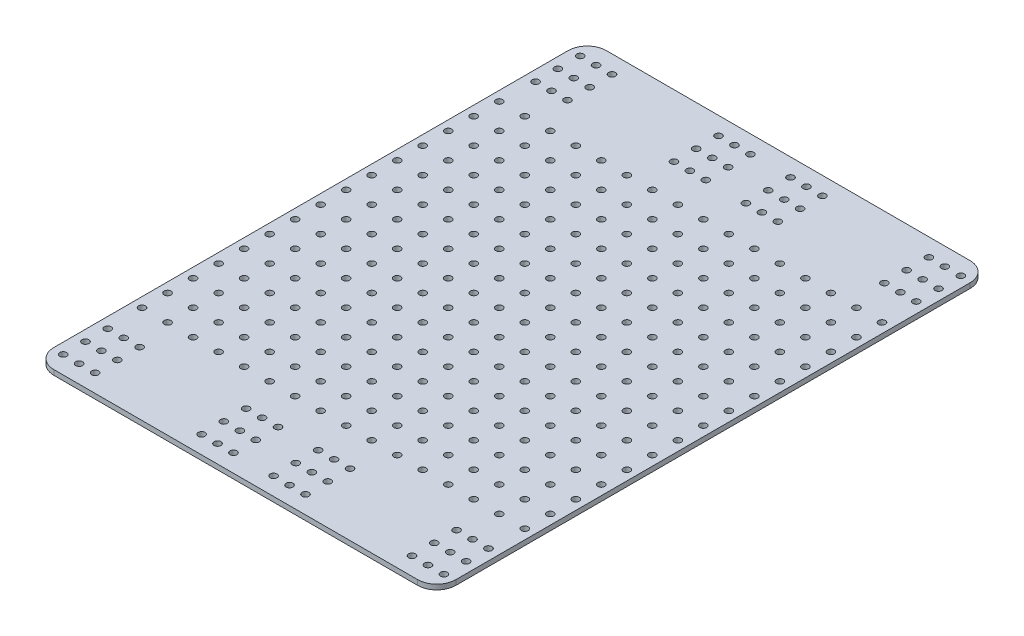
from build123d import *

# Parameters (mm, degrees)
SKETCH2_W            = 200.117666866
SKETCH2_H            = 275
BOSS_EXTRUDE1_DEPTH  = 2.5
M3_CLEARANCE_HOLE1_D = 3.4
MIRROR2_COPY_1_D     = 3.4
FILLET1_R            = 9.525
M3_CLEARANCE_HOLE2_D = 3.4
LPATTERN1_COUNT      = 8
LPATTERN1_PITCH      = 12.7
LPATTERN1_COUNT_DIR2 = 8
LPATTERN1_PITCH_DIR2 = 12.7
MIRROR3_COPY_1_D     = 3.4
MIRROR3_COPY_2_D     = 3.4
MIRROR3_COPY_3_D     = 3.4
MIRROR3_COPY_4_D     = 3.4
MIRROR3_COPY_5_D     = 3.4
MIRROR3_COPY_6_D     = 3.4
MIRROR3_COPY_7_D     = 3.4
MIRROR3_COPY_8_D     = 3.4
MIRROR3_COPY_9_D     = 3.4
MIRROR3_COPY_10_D    = 3.4
MIRROR3_COPY_11_D    = 3.4
MIRROR3_COPY_12_D    = 3.4
MIRROR3_COPY_13_D    = 3.4
MIRROR3_COPY_14_D    = 3.4
MIRROR3_COPY_15_D    = 3.4
MIRROR3_COPY_16_D    = 3.4
MIRROR3_COPY_17_D    = 3.4
MIRROR3_COPY_18_D    = 3.4
MIRROR3_COPY_19_D    = 3.4
MIRROR3_COPY_20_D    = 3.4
MIRROR3_COPY_21_D    = 3.4
MIRROR3_COPY_22_D    = 3.4
MIRROR3_COPY_23_D    = 3.4
MIRROR3_COPY_24_D    = 3.4
MIRROR3_COPY_25_D    = 3.4
MIRROR3_COPY_26_D    = 3.4
MIRROR3_COPY_27_D    = 3.4
MIRROR3_COPY_28_D    = 3.4
MIRROR3_COPY_29_D    = 3.4
MIRROR3_COPY_30_D    = 3.4
MIRROR3_COPY_31_D    = 3.4
MIRROR3_COPY_32_D    = 3.4
MIRROR3_COPY_33_D    = 3.4
MIRROR3_COPY_34_D    = 3.4
MIRROR3_COPY_35_D    = 3.4
MIRROR3_COPY_36_D    = 3.4
MIRROR3_COPY_37_D    = 3.4
MIRROR3_COPY_38_D    = 3.4
MIRROR3_COPY_39_D    = 3.4
MIRROR3_COPY_40_D    = 3.4
MIRROR3_COPY_41_D    = 3.4
MIRROR3_COPY_42_D    = 3.4
MIRROR3_COPY_43_D    = 3.4
MIRROR3_COPY_44_D    = 3.4
MIRROR3_COPY_45_D    = 3.4
MIRROR3_COPY_46_D    = 3.4
MIRROR3_COPY_47_D    = 3.4
MIRROR3_COPY_48_D    = 3.4
MIRROR3_COPY_49_D    = 3.4
MIRROR3_COPY_50_D    = 3.4
MIRROR3_COPY_51_D    = 3.4
MIRROR3_COPY_52_D    = 3.4
MIRROR3_COPY_53_D    = 3.4
MIRROR3_COPY_54_D    = 3.4
MIRROR3_COPY_55_D    = 3.4
MIRROR3_COPY_56_D    = 3.4
MIRROR3_COPY_57_D    = 3.4
MIRROR3_COPY_58_D    = 3.4
MIRROR3_COPY_59_D    = 3.4
MIRROR3_COPY_60_D    = 3.4
MIRROR3_COPY_61_D    = 3.4
MIRROR3_COPY_62_D    = 3.4
MIRROR3_COPY_63_D    = 3.4
MIRROR4_COPY_1_D     = 3.4
MIRROR4_COPY_2_D     = 3.4
MIRROR4_COPY_3_D     = 3.4
MIRROR4_COPY_4_D     = 3.4
MIRROR4_COPY_5_D     = 3.4
MIRROR4_COPY_6_D     = 3.4
MIRROR4_COPY_7_D     = 3.4
MIRROR4_COPY_8_D     = 3.4
MIRROR4_COPY_9_D     = 3.4
MIRROR4_COPY_10_D    = 3.4
MIRROR4_COPY_11_D    = 3.4
MIRROR4_COPY_12_D    = 3.4
MIRROR4_COPY_13_D    = 3.4
MIRROR4_COPY_14_D    = 3.4
MIRROR4_COPY_15_D    = 3.4
MIRROR4_COPY_16_D    = 3.4
MIRROR4_COPY_17_D    = 3.4
MIRROR4_COPY_18_D    = 3.4
MIRROR4_COPY_19_D    = 3.4
MIRROR4_COPY_20_D    = 3.4
MIRROR4_COPY_21_D    = 3.4
MIRROR4_COPY_22_D    = 3.4
MIRROR4_COPY_23_D    = 3.4
MIRROR4_COPY_24_D    = 3.4
MIRROR4_COPY_25_D    = 3.4
MIRROR4_COPY_26_D    = 3.4
MIRROR4_COPY_27_D    = 3.4
MIRROR4_COPY_28_D    = 3.4
MIRROR4_COPY_29_D    = 3.4
MIRROR4_COPY_30_D    = 3.4
MIRROR4_COPY_31_D    = 3.4
MIRROR4_COPY_32_D    = 3.4
MIRROR4_COPY_33_D    = 3.4
MIRROR4_COPY_34_D    = 3.4
MIRROR4_COPY_35_D    = 3.4
MIRROR4_COPY_36_D    = 3.4
MIRROR4_COPY_37_D    = 3.4
MIRROR4_COPY_38_D    = 3.4
MIRROR4_COPY_39_D    = 3.4
MIRROR4_COPY_40_D    = 3.4
MIRROR4_COPY_41_D    = 3.4
MIRROR4_COPY_42_D    = 3.4
MIRROR4_COPY_43_D    = 3.4
MIRROR4_COPY_44_D    = 3.4
MIRROR4_COPY_45_D    = 3.4
MIRROR4_COPY_46_D    = 3.4
MIRROR4_COPY_47_D    = 3.4
MIRROR4_COPY_48_D    = 3.4
MIRROR4_COPY_49_D    = 3.4
MIRROR4_COPY_50_D    = 3.4
MIRROR4_COPY_51_D    = 3.4
MIRROR4_COPY_52_D    = 3.4
MIRROR4_COPY_53_D    = 3.4
MIRROR4_COPY_54_D    = 3.4
MIRROR4_COPY_55_D    = 3.4
MIRROR4_COPY_56_D    = 3.4
MIRROR4_COPY_57_D    = 3.4
MIRROR4_COPY_58_D    = 3.4
MIRROR4_COPY_59_D    = 3.4
MIRROR4_COPY_60_D    = 3.4
MIRROR4_COPY_61_D    = 3.4
MIRROR4_COPY_62_D    = 3.4
MIRROR4_COPY_63_D    = 3.4
MIRROR4_COPY_64_D    = 3.4
MIRROR4_COPY_65_D    = 3.4
MIRROR4_COPY_66_D    = 3.4
MIRROR4_COPY_67_D    = 3.4
MIRROR4_COPY_68_D    = 3.4
MIRROR4_COPY_69_D    = 3.4
MIRROR4_COPY_70_D    = 3.4
MIRROR4_COPY_71_D    = 3.4
MIRROR4_COPY_72_D    = 3.4
MIRROR4_COPY_73_D    = 3.4
MIRROR4_COPY_74_D    = 3.4
MIRROR4_COPY_75_D    = 3.4
MIRROR4_COPY_76_D    = 3.4
MIRROR4_COPY_77_D    = 3.4
MIRROR4_COPY_78_D    = 3.4
MIRROR4_COPY_79_D    = 3.4
MIRROR4_COPY_80_D    = 3.4
MIRROR4_COPY_81_D    = 3.4
MIRROR4_COPY_82_D    = 3.4
MIRROR4_COPY_83_D    = 3.4
MIRROR4_COPY_84_D    = 3.4
MIRROR4_COPY_85_D    = 3.4
MIRROR4_COPY_86_D    = 3.4
MIRROR4_COPY_87_D    = 3.4
MIRROR4_COPY_88_D    = 3.4
MIRROR4_COPY_89_D    = 3.4
MIRROR4_COPY_90_D    = 3.4
MIRROR4_COPY_91_D    = 3.4
MIRROR4_COPY_92_D    = 3.4
MIRROR4_COPY_93_D    = 3.4
MIRROR4_COPY_94_D    = 3.4
MIRROR4_COPY_95_D    = 3.4
MIRROR4_COPY_96_D    = 3.4
MIRROR4_COPY_97_D    = 3.4
MIRROR4_COPY_98_D    = 3.4
MIRROR4_COPY_99_D    = 3.4
MIRROR4_COPY_100_D   = 3.4
MIRROR4_COPY_101_D   = 3.4
MIRROR4_COPY_102_D   = 3.4
MIRROR4_COPY_103_D   = 3.4
MIRROR4_COPY_104_D   = 3.4
MIRROR4_COPY_105_D   = 3.4
MIRROR4_COPY_106_D   = 3.4
MIRROR4_COPY_107_D   = 3.4
MIRROR4_COPY_108_D   = 3.4
MIRROR4_COPY_109_D   = 3.4
MIRROR4_COPY_110_D   = 3.4
MIRROR4_COPY_111_D   = 3.4
MIRROR4_COPY_112_D   = 3.4
MIRROR4_COPY_113_D   = 3.4
MIRROR4_COPY_114_D   = 3.4
MIRROR4_COPY_115_D   = 3.4
MIRROR4_COPY_116_D   = 3.4
MIRROR4_COPY_117_D   = 3.4
MIRROR4_COPY_118_D   = 3.4
MIRROR4_COPY_119_D   = 3.4
MIRROR4_COPY_120_D   = 3.4
MIRROR4_COPY_121_D   = 3.4
MIRROR4_COPY_122_D   = 3.4
MIRROR4_COPY_123_D   = 3.4
MIRROR4_COPY_124_D   = 3.4
MIRROR4_COPY_125_D   = 3.4
MIRROR4_COPY_126_D   = 3.4
MIRROR4_COPY_127_D   = 3.4


with BuildPart() as part:
    # Sketch2 → Boss-Extrude1 (new body)
    with BuildSketch(Plane(origin=(0, 50, 0), x_dir=(1, 0, 0), z_dir=(0, 1, 0))):
        Rectangle(SKETCH2_W, SKETCH2_H)
    extrude(amount=BOSS_EXTRUDE1_DEPTH)

    # M3 Clearance Hole1 (through all)
    with Locations(Plane(origin=(-94.749736615, 52.5, 106.4725), x_dir=(1, 0, 0), z_dir=(0, 1, 0))):
        with Locations((0, 0), (7.9375, 0), (15.875, 0), (15.875, -11.08875), (7.9375, -11.08875), (0, -11.08875), (0, -22.1775), (7.9375, -22.1775), (15.875, -22.1775), (68.893486615, 0), (76.830986615, 0), (84.768486615, 0), (84.768486615, -11.08875), (76.830986615, -11.08875), (68.893486615, -11.08875), (68.893486615, -22.1775), (76.830986615, -22.1775), (84.768486615, -22.1775)):
            m3_clearance_hole1 = Hole(M3_CLEARANCE_HOLE1_D / 2)

    # Mirror1: M3 Clearance Hole1 across plane
    add(m3_clearance_hole1.mirror(Plane(origin=(0, 0, 0), x_dir=(0, 0, 1), z_dir=(1, 0, 0))), mode=Mode.SUBTRACT)

    # Mirror2: M3 Clearance Hole1 across plane
    add(m3_clearance_hole1.mirror(Plane.XY), mode=Mode.SUBTRACT)

    # Mirror2 copy 1 (through all)
    with Locations(Plane(origin=(94.749736615, 52.5, -106.4725), x_dir=(-1, 0, 0), z_dir=(0, 1, 0))):
        with Locations((0, 0), (7.9375, 0), (15.875, 0), (15.875, -11.08875), (7.9375, -11.08875), (0, -11.08875), (0, -22.1775), (7.9375, -22.1775), (15.875, -22.1775), (68.893486615, 0), (76.830986615, 0), (84.768486615, 0), (84.768486615, -11.08875), (76.830986615, -11.08875), (68.893486615, -11.08875), (68.893486615, -22.1775), (76.830986615, -22.1775), (84.768486615, -22.1775)):
            Hole(MIRROR2_COPY_1_D / 2)

    # Fillet1
    fillet1_edges = [part.edges().sort_by_distance(p)[0] for p in [
        (-100.058833433, 51.25, -137.5),
        (100.058833433, 51.25, -137.5),
        (100.058833433, 51.25, 137.5),
        (-100.058833433, 51.25, 137.5),
    ]]
    fillet(fillet1_edges, radius=FILLET1_R)

    # M3 Clearance Hole2 (through all)
    with Locations(Plane(origin=(0, 52.5, 0), x_dir=(1, 0, 0), z_dir=(0, 1, 0))):
        with Locations((6.35, 0)):
            m3_clearance_hole2 = Hole(M3_CLEARANCE_HOLE2_D / 2)

    # LPattern1: M3 Clearance Hole2 8 × 8
    with Locations(*[(j * LPATTERN1_PITCH_DIR2, 0, i * LPATTERN1_PITCH) for i in range(LPATTERN1_COUNT) for j in range(LPATTERN1_COUNT_DIR2) if (i, j) != (0, 0)]):
        add(m3_clearance_hole2, mode=Mode.SUBTRACT)

    # Mirror3: M3 Clearance Hole2 across plane
    add(m3_clearance_hole2.mirror(Plane.XY), mode=Mode.SUBTRACT)

    # Mirror3 copy 1 (through all)
    with Locations(Plane(origin=(12.7, 52.5, 0), x_dir=(1, 0, 0), z_dir=(0, 1, 0))):
        with Locations((6.35, 0)):
            Hole(MIRROR3_COPY_1_D / 2)

    # Mirror3 copy 2 (through all)
    with Locations(Plane(origin=(25.4, 52.5, 0), x_dir=(1, 0, 0), z_dir=(0, 1, 0))):
        with Locations((6.35, 0)):
            Hole(MIRROR3_COPY_2_D / 2)

    # Mirror3 copy 3 (through all)
    with Locations(Plane(origin=(38.1, 52.5, 0), x_dir=(1, 0, 0), z_dir=(0, 1, 0))):
        with Locations((6.35, 0)):
            Hole(MIRROR3_COPY_3_D / 2)

    # Mirror3 copy 4 (through all)
    with Locations(Plane(origin=(50.8, 52.5, 0), x_dir=(1, 0, 0), z_dir=(0, 1, 0))):
        with Locations((6.35, 0)):
            Hole(MIRROR3_COPY_4_D / 2)

    # Mirror3 copy 5 (through all)
    with Locations(Plane(origin=(63.5, 52.5, 0), x_dir=(1, 0, 0), z_dir=(0, 1, 0))):
        with Locations((6.35, 0)):
            Hole(MIRROR3_COPY_5_D / 2)

    # Mirror3 copy 6 (through all)
    with Locations(Plane(origin=(76.2, 52.5, 0), x_dir=(1, 0, 0), z_dir=(0, 1, 0))):
        with Locations((6.35, 0)):
            Hole(MIRROR3_COPY_6_D / 2)

    # Mirror3 copy 7 (through all)
    with Locations(Plane(origin=(88.9, 52.5, 0), x_dir=(1, 0, 0), z_dir=(0, 1, 0))):
        with Locations((6.35, 0)):
            Hole(MIRROR3_COPY_7_D / 2)

    # Mirror3 copy 8 (through all)
    with Locations(Plane(origin=(0, 52.5, -12.7), x_dir=(1, 0, 0), z_dir=(0, 1, 0))):
        with Locations((6.35, 0)):
            Hole(MIRROR3_COPY_8_D / 2)

    # Mirror3 copy 9 (through all)
    with Locations(Plane(origin=(12.7, 52.5, -12.7), x_dir=(1, 0, 0), z_dir=(0, 1, 0))):
        with Locations((6.35, 0)):
            Hole(MIRROR3_COPY_9_D / 2)

    # Mirror3 copy 10 (through all)
    with Locations(Plane(origin=(25.4, 52.5, -12.7), x_dir=(1, 0, 0), z_dir=(0, 1, 0))):
        with Locations((6.35, 0)):
            Hole(MIRROR3_COPY_10_D / 2)

    # Mirror3 copy 11 (through all)
    with Locations(Plane(origin=(38.1, 52.5, -12.7), x_dir=(1, 0, 0), z_dir=(0, 1, 0))):
        with Locations((6.35, 0)):
            Hole(MIRROR3_COPY_11_D / 2)

    # Mirror3 copy 12 (through all)
    with Locations(Plane(origin=(50.8, 52.5, -12.7), x_dir=(1, 0, 0), z_dir=(0, 1, 0))):
        with Locations((6.35, 0)):
            Hole(MIRROR3_COPY_12_D / 2)

    # Mirror3 copy 13 (through all)
    with Locations(Plane(origin=(63.5, 52.5, -12.7), x_dir=(1, 0, 0), z_dir=(0, 1, 0))):
        with Locations((6.35, 0)):
            Hole(MIRROR3_COPY_13_D / 2)

    # Mirror3 copy 14 (through all)
    with Locations(Plane(origin=(76.2, 52.5, -12.7), x_dir=(1, 0, 0), z_dir=(0, 1, 0))):
        with Locations((6.35, 0)):
            Hole(MIRROR3_COPY_14_D / 2)

    # Mirror3 copy 15 (through all)
    with Locations(Plane(origin=(88.9, 52.5, -12.7), x_dir=(1, 0, 0), z_dir=(0, 1, 0))):
        with Locations((6.35, 0)):
            Hole(MIRROR3_COPY_15_D / 2)

    # Mirror3 copy 16 (through all)
    with Locations(Plane(origin=(0, 52.5, -25.4), x_dir=(1, 0, 0), z_dir=(0, 1, 0))):
        with Locations((6.35, 0)):
            Hole(MIRROR3_COPY_16_D / 2)

    # Mirror3 copy 17 (through all)
    with Locations(Plane(origin=(12.7, 52.5, -25.4), x_dir=(1, 0, 0), z_dir=(0, 1, 0))):
        with Locations((6.35, 0)):
            Hole(MIRROR3_COPY_17_D / 2)

    # Mirror3 copy 18 (through all)
    with Locations(Plane(origin=(25.4, 52.5, -25.4), x_dir=(1, 0, 0), z_dir=(0, 1, 0))):
        with Locations((6.35, 0)):
            Hole(MIRROR3_COPY_18_D / 2)

    # Mirror3 copy 19 (through all)
    with Locations(Plane(origin=(38.1, 52.5, -25.4), x_dir=(1, 0, 0), z_dir=(0, 1, 0))):
        with Locations((6.35, 0)):
            Hole(MIRROR3_COPY_19_D / 2)

    # Mirror3 copy 20 (through all)
    with Locations(Plane(origin=(50.8, 52.5, -25.4), x_dir=(1, 0, 0), z_dir=(0, 1, 0))):
        with Locations((6.35, 0)):
            Hole(MIRROR3_COPY_20_D / 2)

    # Mirror3 copy 21 (through all)
    with Locations(Plane(origin=(63.5, 52.5, -25.4), x_dir=(1, 0, 0), z_dir=(0, 1, 0))):
        with Locations((6.35, 0)):
            Hole(MIRROR3_COPY_21_D / 2)

    # Mirror3 copy 22 (through all)
    with Locations(Plane(origin=(76.2, 52.5, -25.4), x_dir=(1, 0, 0), z_dir=(0, 1, 0))):
        with Locations((6.35, 0)):
            Hole(MIRROR3_COPY_22_D / 2)

    # Mirror3 copy 23 (through all)
    with Locations(Plane(origin=(88.9, 52.5, -25.4), x_dir=(1, 0, 0), z_dir=(0, 1, 0))):
        with Locations((6.35, 0)):
            Hole(MIRROR3_COPY_23_D / 2)

    # Mirror3 copy 24 (through all)
    with Locations(Plane(origin=(0, 52.5, -38.1), x_dir=(1, 0, 0), z_dir=(0, 1, 0))):
        with Locations((6.35, 0)):
            Hole(MIRROR3_COPY_24_D / 2)

    # Mirror3 copy 25 (through all)
    with Locations(Plane(origin=(12.7, 52.5, -38.1), x_dir=(1, 0, 0), z_dir=(0, 1, 0))):
        with Locations((6.35, 0)):
            Hole(MIRROR3_COPY_25_D / 2)

    # Mirror3 copy 26 (through all)
    with Locations(Plane(origin=(25.4, 52.5, -38.1), x_dir=(1, 0, 0), z_dir=(0, 1, 0))):
        with Locations((6.35, 0)):
            Hole(MIRROR3_COPY_26_D / 2)

    # Mirror3 copy 27 (through all)
    with Locations(Plane(origin=(38.1, 52.5, -38.1), x_dir=(1, 0, 0), z_dir=(0, 1, 0))):
        with Locations((6.35, 0)):
            Hole(MIRROR3_COPY_27_D / 2)

    # Mirror3 copy 28 (through all)
    with Locations(Plane(origin=(50.8, 52.5, -38.1), x_dir=(1, 0, 0), z_dir=(0, 1, 0))):
        with Locations((6.35, 0)):
            Hole(MIRROR3_COPY_28_D / 2)

    # Mirror3 copy 29 (through all)
    with Locations(Plane(origin=(63.5, 52.5, -38.1), x_dir=(1, 0, 0), z_dir=(0, 1, 0))):
        with Locations((6.35, 0)):
            Hole(MIRROR3_COPY_29_D / 2)

    # Mirror3 copy 30 (through all)
    with Locations(Plane(origin=(76.2, 52.5, -38.1), x_dir=(1, 0, 0), z_dir=(0, 1, 0))):
        with Locations((6.35, 0)):
            Hole(MIRROR3_COPY_30_D / 2)

    # Mirror3 copy 31 (through all)
    with Locations(Plane(origin=(88.9, 52.5, -38.1), x_dir=(1, 0, 0), z_dir=(0, 1, 0))):
        with Locations((6.35, 0)):
            Hole(MIRROR3_COPY_31_D / 2)

    # Mirror3 copy 32 (through all)
    with Locations(Plane(origin=(0, 52.5, -50.8), x_dir=(1, 0, 0), z_dir=(0, 1, 0))):
        with Locations((6.35, 0)):
            Hole(MIRROR3_COPY_32_D / 2)

    # Mirror3 copy 33 (through all)
    with Locations(Plane(origin=(12.7, 52.5, -50.8), x_dir=(1, 0, 0), z_dir=(0, 1, 0))):
        with Locations((6.35, 0)):
            Hole(MIRROR3_COPY_33_D / 2)

    # Mirror3 copy 34 (through all)
    with Locations(Plane(origin=(25.4, 52.5, -50.8), x_dir=(1, 0, 0), z_dir=(0, 1, 0))):
        with Locations((6.35, 0)):
            Hole(MIRROR3_COPY_34_D / 2)

    # Mirror3 copy 35 (through all)
    with Locations(Plane(origin=(38.1, 52.5, -50.8), x_dir=(1, 0, 0), z_dir=(0, 1, 0))):
        with Locations((6.35, 0)):
            Hole(MIRROR3_COPY_35_D / 2)

    # Mirror3 copy 36 (through all)
    with Locations(Plane(origin=(50.8, 52.5, -50.8), x_dir=(1, 0, 0), z_dir=(0, 1, 0))):
        with Locations((6.35, 0)):
            Hole(MIRROR3_COPY_36_D / 2)

    # Mirror3 copy 37 (through all)
    with Locations(Plane(origin=(63.5, 52.5, -50.8), x_dir=(1, 0, 0), z_dir=(0, 1, 0))):
        with Locations((6.35, 0)):
            Hole(MIRROR3_COPY_37_D / 2)

    # Mirror3 copy 38 (through all)
    with Locations(Plane(origin=(76.2, 52.5, -50.8), x_dir=(1, 0, 0), z_dir=(0, 1, 0))):
        with Locations((6.35, 0)):
            Hole(MIRROR3_COPY_38_D / 2)

    # Mirror3 copy 39 (through all)
    with Locations(Plane(origin=(88.9, 52.5, -50.8), x_dir=(1, 0, 0), z_dir=(0, 1, 0))):
        with Locations((6.35, 0)):
            Hole(MIRROR3_COPY_39_D / 2)

    # Mirror3 copy 40 (through all)
    with Locations(Plane(origin=(0, 52.5, -63.5), x_dir=(1, 0, 0), z_dir=(0, 1, 0))):
        with Locations((6.35, 0)):
            Hole(MIRROR3_COPY_40_D / 2)

    # Mirror3 copy 41 (through all)
    with Locations(Plane(origin=(12.7, 52.5, -63.5), x_dir=(1, 0, 0), z_dir=(0, 1, 0))):
        with Locations((6.35, 0)):
            Hole(MIRROR3_COPY_41_D / 2)

    # Mirror3 copy 42 (through all)
    with Locations(Plane(origin=(25.4, 52.5, -63.5), x_dir=(1, 0, 0), z_dir=(0, 1, 0))):
        with Locations((6.35, 0)):
            Hole(MIRROR3_COPY_42_D / 2)

    # Mirror3 copy 43 (through all)
    with Locations(Plane(origin=(38.1, 52.5, -63.5), x_dir=(1, 0, 0), z_dir=(0, 1, 0))):
        with Locations((6.35, 0)):
            Hole(MIRROR3_COPY_43_D / 2)

    # Mirror3 copy 44 (through all)
    with Locations(Plane(origin=(50.8, 52.5, -63.5), x_dir=(1, 0, 0), z_dir=(0, 1, 0))):
        with Locations((6.35, 0)):
            Hole(MIRROR3_COPY_44_D / 2)

    # Mirror3 copy 45 (through all)
    with Locations(Plane(origin=(63.5, 52.5, -63.5), x_dir=(1, 0, 0), z_dir=(0, 1, 0))):
        with Locations((6.35, 0)):
            Hole(MIRROR3_COPY_45_D / 2)

    # Mirror3 copy 46 (through all)
    with Locations(Plane(origin=(76.2, 52.5, -63.5), x_dir=(1, 0, 0), z_dir=(0, 1, 0))):
        with Locations((6.35, 0)):
            Hole(MIRROR3_COPY_46_D / 2)

    # Mirror3 copy 47 (through all)
    with Locations(Plane(origin=(88.9, 52.5, -63.5), x_dir=(1, 0, 0), z_dir=(0, 1, 0))):
        with Locations((6.35, 0)):
            Hole(MIRROR3_COPY_47_D / 2)

    # Mirror3 copy 48 (through all)
    with Locations(Plane(origin=(0, 52.5, -76.2), x_dir=(1, 0, 0), z_dir=(0, 1, 0))):
        with Locations((6.35, 0)):
            Hole(MIRROR3_COPY_48_D / 2)

    # Mirror3 copy 49 (through all)
    with Locations(Plane(origin=(12.7, 52.5, -76.2), x_dir=(1, 0, 0), z_dir=(0, 1, 0))):
        with Locations((6.35, 0)):
            Hole(MIRROR3_COPY_49_D / 2)

    # Mirror3 copy 50 (through all)
    with Locations(Plane(origin=(25.4, 52.5, -76.2), x_dir=(1, 0, 0), z_dir=(0, 1, 0))):
        with Locations((6.35, 0)):
            Hole(MIRROR3_COPY_50_D / 2)

    # Mirror3 copy 51 (through all)
    with Locations(Plane(origin=(38.1, 52.5, -76.2), x_dir=(1, 0, 0), z_dir=(0, 1, 0))):
        with Locations((6.35, 0)):
            Hole(MIRROR3_COPY_51_D / 2)

    # Mirror3 copy 52 (through all)
    with Locations(Plane(origin=(50.8, 52.5, -76.2), x_dir=(1, 0, 0), z_dir=(0, 1, 0))):
        with Locations((6.35, 0)):
            Hole(MIRROR3_COPY_52_D / 2)

    # Mirror3 copy 53 (through all)
    with Locations(Plane(origin=(63.5, 52.5, -76.2), x_dir=(1, 0, 0), z_dir=(0, 1, 0))):
        with Locations((6.35, 0)):
            Hole(MIRROR3_COPY_53_D / 2)

    # Mirror3 copy 54 (through all)
    with Locations(Plane(origin=(76.2, 52.5, -76.2), x_dir=(1, 0, 0), z_dir=(0, 1, 0))):
        with Locations((6.35, 0)):
            Hole(MIRROR3_COPY_54_D / 2)

    # Mirror3 copy 55 (through all)
    with Locations(Plane(origin=(88.9, 52.5, -76.2), x_dir=(1, 0, 0), z_dir=(0, 1, 0))):
        with Locations((6.35, 0)):
            Hole(MIRROR3_COPY_55_D / 2)

    # Mirror3 copy 56 (through all)
    with Locations(Plane(origin=(0, 52.5, -88.9), x_dir=(1, 0, 0), z_dir=(0, 1, 0))):
        with Locations((6.35, 0)):
            Hole(MIRROR3_COPY_56_D / 2)

    # Mirror3 copy 57 (through all)
    with Locations(Plane(origin=(12.7, 52.5, -88.9), x_dir=(1, 0, 0), z_dir=(0, 1, 0))):
        with Locations((6.35, 0)):
            Hole(MIRROR3_COPY_57_D / 2)

    # Mirror3 copy 58 (through all)
    with Locations(Plane(origin=(25.4, 52.5, -88.9), x_dir=(1, 0, 0), z_dir=(0, 1, 0))):
        with Locations((6.35, 0)):
            Hole(MIRROR3_COPY_58_D / 2)

    # Mirror3 copy 59 (through all)
    with Locations(Plane(origin=(38.1, 52.5, -88.9), x_dir=(1, 0, 0), z_dir=(0, 1, 0))):
        with Locations((6.35, 0)):
            Hole(MIRROR3_COPY_59_D / 2)

    # Mirror3 copy 60 (through all)
    with Locations(Plane(origin=(50.8, 52.5, -88.9), x_dir=(1, 0, 0), z_dir=(0, 1, 0))):
        with Locations((6.35, 0)):
            Hole(MIRROR3_COPY_60_D / 2)

    # Mirror3 copy 61 (through all)
    with Locations(Plane(origin=(63.5, 52.5, -88.9), x_dir=(1, 0, 0), z_dir=(0, 1, 0))):
        with Locations((6.35, 0)):
            Hole(MIRROR3_COPY_61_D / 2)

    # Mirror3 copy 62 (through all)
    with Locations(Plane(origin=(76.2, 52.5, -88.9), x_dir=(1, 0, 0), z_dir=(0, 1, 0))):
        with Locations((6.35, 0)):
            Hole(MIRROR3_COPY_62_D / 2)

    # Mirror3 copy 63 (through all)
    with Locations(Plane(origin=(88.9, 52.5, -88.9), x_dir=(1, 0, 0), z_dir=(0, 1, 0))):
        with Locations((6.35, 0)):
            Hole(MIRROR3_COPY_63_D / 2)

    # Mirror4: M3 Clearance Hole2 across plane
    add(m3_clearance_hole2.mirror(Plane(origin=(0, 0, 0), x_dir=(0, 0, 1), z_dir=(1, 0, 0))), mode=Mode.SUBTRACT)

    # Mirror4 copy 1 (through all)
    with Locations(Plane(origin=(-12.7, 52.5, 0), x_dir=(-1, 0, 0), z_dir=(0, 1, 0))):
        with Locations((6.35, 0)):
            Hole(MIRROR4_COPY_1_D / 2)

    # Mirror4 copy 2 (through all)
    with Locations(Plane(origin=(-25.4, 52.5, 0), x_dir=(-1, 0, 0), z_dir=(0, 1, 0))):
        with Locations((6.35, 0)):
            Hole(MIRROR4_COPY_2_D / 2)

    # Mirror4 copy 3 (through all)
    with Locations(Plane(origin=(-38.1, 52.5, 0), x_dir=(-1, 0, 0), z_dir=(0, 1, 0))):
        with Locations((6.35, 0)):
            Hole(MIRROR4_COPY_3_D / 2)

    # Mirror4 copy 4 (through all)
    with Locations(Plane(origin=(-50.8, 52.5, 0), x_dir=(-1, 0, 0), z_dir=(0, 1, 0))):
        with Locations((6.35, 0)):
            Hole(MIRROR4_COPY_4_D / 2)

    # Mirror4 copy 5 (through all)
    with Locations(Plane(origin=(-63.5, 52.5, 0), x_dir=(-1, 0, 0), z_dir=(0, 1, 0))):
        with Locations((6.35, 0)):
            Hole(MIRROR4_COPY_5_D / 2)

    # Mirror4 copy 6 (through all)
    with Locations(Plane(origin=(-76.2, 52.5, 0), x_dir=(-1, 0, 0), z_dir=(0, 1, 0))):
        with Locations((6.35, 0)):
            Hole(MIRROR4_COPY_6_D / 2)

    # Mirror4 copy 7 (through all)
    with Locations(Plane(origin=(-88.9, 52.5, 0), x_dir=(-1, 0, 0), z_dir=(0, 1, 0))):
        with Locations((6.35, 0)):
            Hole(MIRROR4_COPY_7_D / 2)

    # Mirror4 copy 8 (through all)
    with Locations(Plane(origin=(0, 52.5, 12.7), x_dir=(-1, 0, 0), z_dir=(0, 1, 0))):
        with Locations((6.35, 0)):
            Hole(MIRROR4_COPY_8_D / 2)

    # Mirror4 copy 9 (through all)
    with Locations(Plane(origin=(-12.7, 52.5, 12.7), x_dir=(-1, 0, 0), z_dir=(0, 1, 0))):
        with Locations((6.35, 0)):
            Hole(MIRROR4_COPY_9_D / 2)

    # Mirror4 copy 10 (through all)
    with Locations(Plane(origin=(-25.4, 52.5, 12.7), x_dir=(-1, 0, 0), z_dir=(0, 1, 0))):
        with Locations((6.35, 0)):
            Hole(MIRROR4_COPY_10_D / 2)

    # Mirror4 copy 11 (through all)
    with Locations(Plane(origin=(-38.1, 52.5, 12.7), x_dir=(-1, 0, 0), z_dir=(0, 1, 0))):
        with Locations((6.35, 0)):
            Hole(MIRROR4_COPY_11_D / 2)

    # Mirror4 copy 12 (through all)
    with Locations(Plane(origin=(-50.8, 52.5, 12.7), x_dir=(-1, 0, 0), z_dir=(0, 1, 0))):
        with Locations((6.35, 0)):
            Hole(MIRROR4_COPY_12_D / 2)

    # Mirror4 copy 13 (through all)
    with Locations(Plane(origin=(-63.5, 52.5, 12.7), x_dir=(-1, 0, 0), z_dir=(0, 1, 0))):
        with Locations((6.35, 0)):
            Hole(MIRROR4_COPY_13_D / 2)

    # Mirror4 copy 14 (through all)
    with Locations(Plane(origin=(-76.2, 52.5, 12.7), x_dir=(-1, 0, 0), z_dir=(0, 1, 0))):
        with Locations((6.35, 0)):
            Hole(MIRROR4_COPY_14_D / 2)

    # Mirror4 copy 15 (through all)
    with Locations(Plane(origin=(-88.9, 52.5, 12.7), x_dir=(-1, 0, 0), z_dir=(0, 1, 0))):
        with Locations((6.35, 0)):
            Hole(MIRROR4_COPY_15_D / 2)

    # Mirror4 copy 16 (through all)
    with Locations(Plane(origin=(0, 52.5, 25.4), x_dir=(-1, 0, 0), z_dir=(0, 1, 0))):
        with Locations((6.35, 0)):
            Hole(MIRROR4_COPY_16_D / 2)

    # Mirror4 copy 17 (through all)
    with Locations(Plane(origin=(-12.7, 52.5, 25.4), x_dir=(-1, 0, 0), z_dir=(0, 1, 0))):
        with Locations((6.35, 0)):
            Hole(MIRROR4_COPY_17_D / 2)

    # Mirror4 copy 18 (through all)
    with Locations(Plane(origin=(-25.4, 52.5, 25.4), x_dir=(-1, 0, 0), z_dir=(0, 1, 0))):
        with Locations((6.35, 0)):
            Hole(MIRROR4_COPY_18_D / 2)

    # Mirror4 copy 19 (through all)
    with Locations(Plane(origin=(-38.1, 52.5, 25.4), x_dir=(-1, 0, 0), z_dir=(0, 1, 0))):
        with Locations((6.35, 0)):
            Hole(MIRROR4_COPY_19_D / 2)

    # Mirror4 copy 20 (through all)
    with Locations(Plane(origin=(-50.8, 52.5, 25.4), x_dir=(-1, 0, 0), z_dir=(0, 1, 0))):
        with Locations((6.35, 0)):
            Hole(MIRROR4_COPY_20_D / 2)

    # Mirror4 copy 21 (through all)
    with Locations(Plane(origin=(-63.5, 52.5, 25.4), x_dir=(-1, 0, 0), z_dir=(0, 1, 0))):
        with Locations((6.35, 0)):
            Hole(MIRROR4_COPY_21_D / 2)

    # Mirror4 copy 22 (through all)
    with Locations(Plane(origin=(-76.2, 52.5, 25.4), x_dir=(-1, 0, 0), z_dir=(0, 1, 0))):
        with Locations((6.35, 0)):
            Hole(MIRROR4_COPY_22_D / 2)

    # Mirror4 copy 23 (through all)
    with Locations(Plane(origin=(-88.9, 52.5, 25.4), x_dir=(-1, 0, 0), z_dir=(0, 1, 0))):
        with Locations((6.35, 0)):
            Hole(MIRROR4_COPY_23_D / 2)

    # Mirror4 copy 24 (through all)
    with Locations(Plane(origin=(0, 52.5, 38.1), x_dir=(-1, 0, 0), z_dir=(0, 1, 0))):
        with Locations((6.35, 0)):
            Hole(MIRROR4_COPY_24_D / 2)

    # Mirror4 copy 25 (through all)
    with Locations(Plane(origin=(-12.7, 52.5, 38.1), x_dir=(-1, 0, 0), z_dir=(0, 1, 0))):
        with Locations((6.35, 0)):
            Hole(MIRROR4_COPY_25_D / 2)

    # Mirror4 copy 26 (through all)
    with Locations(Plane(origin=(-25.4, 52.5, 38.1), x_dir=(-1, 0, 0), z_dir=(0, 1, 0))):
        with Locations((6.35, 0)):
            Hole(MIRROR4_COPY_26_D / 2)

    # Mirror4 copy 27 (through all)
    with Locations(Plane(origin=(-38.1, 52.5, 38.1), x_dir=(-1, 0, 0), z_dir=(0, 1, 0))):
        with Locations((6.35, 0)):
            Hole(MIRROR4_COPY_27_D / 2)

    # Mirror4 copy 28 (through all)
    with Locations(Plane(origin=(-50.8, 52.5, 38.1), x_dir=(-1, 0, 0), z_dir=(0, 1, 0))):
        with Locations((6.35, 0)):
            Hole(MIRROR4_COPY_28_D / 2)

    # Mirror4 copy 29 (through all)
    with Locations(Plane(origin=(-63.5, 52.5, 38.1), x_dir=(-1, 0, 0), z_dir=(0, 1, 0))):
        with Locations((6.35, 0)):
            Hole(MIRROR4_COPY_29_D / 2)

    # Mirror4 copy 30 (through all)
    with Locations(Plane(origin=(-76.2, 52.5, 38.1), x_dir=(-1, 0, 0), z_dir=(0, 1, 0))):
        with Locations((6.35, 0)):
            Hole(MIRROR4_COPY_30_D / 2)

    # Mirror4 copy 31 (through all)
    with Locations(Plane(origin=(-88.9, 52.5, 38.1), x_dir=(-1, 0, 0), z_dir=(0, 1, 0))):
        with Locations((6.35, 0)):
            Hole(MIRROR4_COPY_31_D / 2)

    # Mirror4 copy 32 (through all)
    with Locations(Plane(origin=(0, 52.5, 50.8), x_dir=(-1, 0, 0), z_dir=(0, 1, 0))):
        with Locations((6.35, 0)):
            Hole(MIRROR4_COPY_32_D / 2)

    # Mirror4 copy 33 (through all)
    with Locations(Plane(origin=(-12.7, 52.5, 50.8), x_dir=(-1, 0, 0), z_dir=(0, 1, 0))):
        with Locations((6.35, 0)):
            Hole(MIRROR4_COPY_33_D / 2)

    # Mirror4 copy 34 (through all)
    with Locations(Plane(origin=(-25.4, 52.5, 50.8), x_dir=(-1, 0, 0), z_dir=(0, 1, 0))):
        with Locations((6.35, 0)):
            Hole(MIRROR4_COPY_34_D / 2)

    # Mirror4 copy 35 (through all)
    with Locations(Plane(origin=(-38.1, 52.5, 50.8), x_dir=(-1, 0, 0), z_dir=(0, 1, 0))):
        with Locations((6.35, 0)):
            Hole(MIRROR4_COPY_35_D / 2)

    # Mirror4 copy 36 (through all)
    with Locations(Plane(origin=(-50.8, 52.5, 50.8), x_dir=(-1, 0, 0), z_dir=(0, 1, 0))):
        with Locations((6.35, 0)):
            Hole(MIRROR4_COPY_36_D / 2)

    # Mirror4 copy 37 (through all)
    with Locations(Plane(origin=(-63.5, 52.5, 50.8), x_dir=(-1, 0, 0), z_dir=(0, 1, 0))):
        with Locations((6.35, 0)):
            Hole(MIRROR4_COPY_37_D / 2)

    # Mirror4 copy 38 (through all)
    with Locations(Plane(origin=(-76.2, 52.5, 50.8), x_dir=(-1, 0, 0), z_dir=(0, 1, 0))):
        with Locations((6.35, 0)):
            Hole(MIRROR4_COPY_38_D / 2)

    # Mirror4 copy 39 (through all)
    with Locations(Plane(origin=(-88.9, 52.5, 50.8), x_dir=(-1, 0, 0), z_dir=(0, 1, 0))):
        with Locations((6.35, 0)):
            Hole(MIRROR4_COPY_39_D / 2)

    # Mirror4 copy 40 (through all)
    with Locations(Plane(origin=(0, 52.5, 63.5), x_dir=(-1, 0, 0), z_dir=(0, 1, 0))):
        with Locations((6.35, 0)):
            Hole(MIRROR4_COPY_40_D / 2)

    # Mirror4 copy 41 (through all)
    with Locations(Plane(origin=(-12.7, 52.5, 63.5), x_dir=(-1, 0, 0), z_dir=(0, 1, 0))):
        with Locations((6.35, 0)):
            Hole(MIRROR4_COPY_41_D / 2)

    # Mirror4 copy 42 (through all)
    with Locations(Plane(origin=(-25.4, 52.5, 63.5), x_dir=(-1, 0, 0), z_dir=(0, 1, 0))):
        with Locations((6.35, 0)):
            Hole(MIRROR4_COPY_42_D / 2)

    # Mirror4 copy 43 (through all)
    with Locations(Plane(origin=(-38.1, 52.5, 63.5), x_dir=(-1, 0, 0), z_dir=(0, 1, 0))):
        with Locations((6.35, 0)):
            Hole(MIRROR4_COPY_43_D / 2)

    # Mirror4 copy 44 (through all)
    with Locations(Plane(origin=(-50.8, 52.5, 63.5), x_dir=(-1, 0, 0), z_dir=(0, 1, 0))):
        with Locations((6.35, 0)):
            Hole(MIRROR4_COPY_44_D / 2)

    # Mirror4 copy 45 (through all)
    with Locations(Plane(origin=(-63.5, 52.5, 63.5), x_dir=(-1, 0, 0), z_dir=(0, 1, 0))):
        with Locations((6.35, 0)):
            Hole(MIRROR4_COPY_45_D / 2)

    # Mirror4 copy 46 (through all)
    with Locations(Plane(origin=(-76.2, 52.5, 63.5), x_dir=(-1, 0, 0), z_dir=(0, 1, 0))):
        with Locations((6.35, 0)):
            Hole(MIRROR4_COPY_46_D / 2)

    # Mirror4 copy 47 (through all)
    with Locations(Plane(origin=(-88.9, 52.5, 63.5), x_dir=(-1, 0, 0), z_dir=(0, 1, 0))):
        with Locations((6.35, 0)):
            Hole(MIRROR4_COPY_47_D / 2)

    # Mirror4 copy 48 (through all)
    with Locations(Plane(origin=(0, 52.5, 76.2), x_dir=(-1, 0, 0), z_dir=(0, 1, 0))):
        with Locations((6.35, 0)):
            Hole(MIRROR4_COPY_48_D / 2)

    # Mirror4 copy 49 (through all)
    with Locations(Plane(origin=(-12.7, 52.5, 76.2), x_dir=(-1, 0, 0), z_dir=(0, 1, 0))):
        with Locations((6.35, 0)):
            Hole(MIRROR4_COPY_49_D / 2)

    # Mirror4 copy 50 (through all)
    with Locations(Plane(origin=(-25.4, 52.5, 76.2), x_dir=(-1, 0, 0), z_dir=(0, 1, 0))):
        with Locations((6.35, 0)):
            Hole(MIRROR4_COPY_50_D / 2)

    # Mirror4 copy 51 (through all)
    with Locations(Plane(origin=(-38.1, 52.5, 76.2), x_dir=(-1, 0, 0), z_dir=(0, 1, 0))):
        with Locations((6.35, 0)):
            Hole(MIRROR4_COPY_51_D / 2)

    # Mirror4 copy 52 (through all)
    with Locations(Plane(origin=(-50.8, 52.5, 76.2), x_dir=(-1, 0, 0), z_dir=(0, 1, 0))):
        with Locations((6.35, 0)):
            Hole(MIRROR4_COPY_52_D / 2)

    # Mirror4 copy 53 (through all)
    with Locations(Plane(origin=(-63.5, 52.5, 76.2), x_dir=(-1, 0, 0), z_dir=(0, 1, 0))):
        with Locations((6.35, 0)):
            Hole(MIRROR4_COPY_53_D / 2)

    # Mirror4 copy 54 (through all)
    with Locations(Plane(origin=(-76.2, 52.5, 76.2), x_dir=(-1, 0, 0), z_dir=(0, 1, 0))):
        with Locations((6.35, 0)):
            Hole(MIRROR4_COPY_54_D / 2)

    # Mirror4 copy 55 (through all)
    with Locations(Plane(origin=(-88.9, 52.5, 76.2), x_dir=(-1, 0, 0), z_dir=(0, 1, 0))):
        with Locations((6.35, 0)):
            Hole(MIRROR4_COPY_55_D / 2)

    # Mirror4 copy 56 (through all)
    with Locations(Plane(origin=(0, 52.5, 88.9), x_dir=(-1, 0, 0), z_dir=(0, 1, 0))):
        with Locations((6.35, 0)):
            Hole(MIRROR4_COPY_56_D / 2)

    # Mirror4 copy 57 (through all)
    with Locations(Plane(origin=(-12.7, 52.5, 88.9), x_dir=(-1, 0, 0), z_dir=(0, 1, 0))):
        with Locations((6.35, 0)):
            Hole(MIRROR4_COPY_57_D / 2)

    # Mirror4 copy 58 (through all)
    with Locations(Plane(origin=(-25.4, 52.5, 88.9), x_dir=(-1, 0, 0), z_dir=(0, 1, 0))):
        with Locations((6.35, 0)):
            Hole(MIRROR4_COPY_58_D / 2)

    # Mirror4 copy 59 (through all)
    with Locations(Plane(origin=(-38.1, 52.5, 88.9), x_dir=(-1, 0, 0), z_dir=(0, 1, 0))):
        with Locations((6.35, 0)):
            Hole(MIRROR4_COPY_59_D / 2)

    # Mirror4 copy 60 (through all)
    with Locations(Plane(origin=(-50.8, 52.5, 88.9), x_dir=(-1, 0, 0), z_dir=(0, 1, 0))):
        with Locations((6.35, 0)):
            Hole(MIRROR4_COPY_60_D / 2)

    # Mirror4 copy 61 (through all)
    with Locations(Plane(origin=(-63.5, 52.5, 88.9), x_dir=(-1, 0, 0), z_dir=(0, 1, 0))):
        with Locations((6.35, 0)):
            Hole(MIRROR4_COPY_61_D / 2)

    # Mirror4 copy 62 (through all)
    with Locations(Plane(origin=(-76.2, 52.5, 88.9), x_dir=(-1, 0, 0), z_dir=(0, 1, 0))):
        with Locations((6.35, 0)):
            Hole(MIRROR4_COPY_62_D / 2)

    # Mirror4 copy 63 (through all)
    with Locations(Plane(origin=(-88.9, 52.5, 88.9), x_dir=(-1, 0, 0), z_dir=(0, 1, 0))):
        with Locations((6.35, 0)):
            Hole(MIRROR4_COPY_63_D / 2)

    # Mirror4 copy 64 (through all)
    with Locations(Plane(origin=(0, 52.5, 0), x_dir=(-1, 0, 0), z_dir=(0, 1, 0))):
        with Locations((6.35, 0)):
            Hole(MIRROR4_COPY_64_D / 2)

    # Mirror4 copy 65 (through all)
    with Locations(Plane(origin=(-12.7, 52.5, 0), x_dir=(-1, 0, 0), z_dir=(0, 1, 0))):
        with Locations((6.35, 0)):
            Hole(MIRROR4_COPY_65_D / 2)

    # Mirror4 copy 66 (through all)
    with Locations(Plane(origin=(-25.4, 52.5, 0), x_dir=(-1, 0, 0), z_dir=(0, 1, 0))):
        with Locations((6.35, 0)):
            Hole(MIRROR4_COPY_66_D / 2)

    # Mirror4 copy 67 (through all)
    with Locations(Plane(origin=(-38.1, 52.5, 0), x_dir=(-1, 0, 0), z_dir=(0, 1, 0))):
        with Locations((6.35, 0)):
            Hole(MIRROR4_COPY_67_D / 2)

    # Mirror4 copy 68 (through all)
    with Locations(Plane(origin=(-50.8, 52.5, 0), x_dir=(-1, 0, 0), z_dir=(0, 1, 0))):
        with Locations((6.35, 0)):
            Hole(MIRROR4_COPY_68_D / 2)

    # Mirror4 copy 69 (through all)
    with Locations(Plane(origin=(-63.5, 52.5, 0), x_dir=(-1, 0, 0), z_dir=(0, 1, 0))):
        with Locations((6.35, 0)):
            Hole(MIRROR4_COPY_69_D / 2)

    # Mirror4 copy 70 (through all)
    with Locations(Plane(origin=(-76.2, 52.5, 0), x_dir=(-1, 0, 0), z_dir=(0, 1, 0))):
        with Locations((6.35, 0)):
            Hole(MIRROR4_COPY_70_D / 2)

    # Mirror4 copy 71 (through all)
    with Locations(Plane(origin=(-88.9, 52.5, 0), x_dir=(-1, 0, 0), z_dir=(0, 1, 0))):
        with Locations((6.35, 0)):
            Hole(MIRROR4_COPY_71_D / 2)

    # Mirror4 copy 72 (through all)
    with Locations(Plane(origin=(0, 52.5, -12.7), x_dir=(-1, 0, 0), z_dir=(0, 1, 0))):
        with Locations((6.35, 0)):
            Hole(MIRROR4_COPY_72_D / 2)

    # Mirror4 copy 73 (through all)
    with Locations(Plane(origin=(-12.7, 52.5, -12.7), x_dir=(-1, 0, 0), z_dir=(0, 1, 0))):
        with Locations((6.35, 0)):
            Hole(MIRROR4_COPY_73_D / 2)

    # Mirror4 copy 74 (through all)
    with Locations(Plane(origin=(-25.4, 52.5, -12.7), x_dir=(-1, 0, 0), z_dir=(0, 1, 0))):
        with Locations((6.35, 0)):
            Hole(MIRROR4_COPY_74_D / 2)

    # Mirror4 copy 75 (through all)
    with Locations(Plane(origin=(-38.1, 52.5, -12.7), x_dir=(-1, 0, 0), z_dir=(0, 1, 0))):
        with Locations((6.35, 0)):
            Hole(MIRROR4_COPY_75_D / 2)

    # Mirror4 copy 76 (through all)
    with Locations(Plane(origin=(-50.8, 52.5, -12.7), x_dir=(-1, 0, 0), z_dir=(0, 1, 0))):
        with Locations((6.35, 0)):
            Hole(MIRROR4_COPY_76_D / 2)

    # Mirror4 copy 77 (through all)
    with Locations(Plane(origin=(-63.5, 52.5, -12.7), x_dir=(-1, 0, 0), z_dir=(0, 1, 0))):
        with Locations((6.35, 0)):
            Hole(MIRROR4_COPY_77_D / 2)

    # Mirror4 copy 78 (through all)
    with Locations(Plane(origin=(-76.2, 52.5, -12.7), x_dir=(-1, 0, 0), z_dir=(0, 1, 0))):
        with Locations((6.35, 0)):
            Hole(MIRROR4_COPY_78_D / 2)

    # Mirror4 copy 79 (through all)
    with Locations(Plane(origin=(-88.9, 52.5, -12.7), x_dir=(-1, 0, 0), z_dir=(0, 1, 0))):
        with Locations((6.35, 0)):
            Hole(MIRROR4_COPY_79_D / 2)

    # Mirror4 copy 80 (through all)
    with Locations(Plane(origin=(0, 52.5, -25.4), x_dir=(-1, 0, 0), z_dir=(0, 1, 0))):
        with Locations((6.35, 0)):
            Hole(MIRROR4_COPY_80_D / 2)

    # Mirror4 copy 81 (through all)
    with Locations(Plane(origin=(-12.7, 52.5, -25.4), x_dir=(-1, 0, 0), z_dir=(0, 1, 0))):
        with Locations((6.35, 0)):
            Hole(MIRROR4_COPY_81_D / 2)

    # Mirror4 copy 82 (through all)
    with Locations(Plane(origin=(-25.4, 52.5, -25.4), x_dir=(-1, 0, 0), z_dir=(0, 1, 0))):
        with Locations((6.35, 0)):
            Hole(MIRROR4_COPY_82_D / 2)

    # Mirror4 copy 83 (through all)
    with Locations(Plane(origin=(-38.1, 52.5, -25.4), x_dir=(-1, 0, 0), z_dir=(0, 1, 0))):
        with Locations((6.35, 0)):
            Hole(MIRROR4_COPY_83_D / 2)

    # Mirror4 copy 84 (through all)
    with Locations(Plane(origin=(-50.8, 52.5, -25.4), x_dir=(-1, 0, 0), z_dir=(0, 1, 0))):
        with Locations((6.35, 0)):
            Hole(MIRROR4_COPY_84_D / 2)

    # Mirror4 copy 85 (through all)
    with Locations(Plane(origin=(-63.5, 52.5, -25.4), x_dir=(-1, 0, 0), z_dir=(0, 1, 0))):
        with Locations((6.35, 0)):
            Hole(MIRROR4_COPY_85_D / 2)

    # Mirror4 copy 86 (through all)
    with Locations(Plane(origin=(-76.2, 52.5, -25.4), x_dir=(-1, 0, 0), z_dir=(0, 1, 0))):
        with Locations((6.35, 0)):
            Hole(MIRROR4_COPY_86_D / 2)

    # Mirror4 copy 87 (through all)
    with Locations(Plane(origin=(-88.9, 52.5, -25.4), x_dir=(-1, 0, 0), z_dir=(0, 1, 0))):
        with Locations((6.35, 0)):
            Hole(MIRROR4_COPY_87_D / 2)

    # Mirror4 copy 88 (through all)
    with Locations(Plane(origin=(0, 52.5, -38.1), x_dir=(-1, 0, 0), z_dir=(0, 1, 0))):
        with Locations((6.35, 0)):
            Hole(MIRROR4_COPY_88_D / 2)

    # Mirror4 copy 89 (through all)
    with Locations(Plane(origin=(-12.7, 52.5, -38.1), x_dir=(-1, 0, 0), z_dir=(0, 1, 0))):
        with Locations((6.35, 0)):
            Hole(MIRROR4_COPY_89_D / 2)

    # Mirror4 copy 90 (through all)
    with Locations(Plane(origin=(-25.4, 52.5, -38.1), x_dir=(-1, 0, 0), z_dir=(0, 1, 0))):
        with Locations((6.35, 0)):
            Hole(MIRROR4_COPY_90_D / 2)

    # Mirror4 copy 91 (through all)
    with Locations(Plane(origin=(-38.1, 52.5, -38.1), x_dir=(-1, 0, 0), z_dir=(0, 1, 0))):
        with Locations((6.35, 0)):
            Hole(MIRROR4_COPY_91_D / 2)

    # Mirror4 copy 92 (through all)
    with Locations(Plane(origin=(-50.8, 52.5, -38.1), x_dir=(-1, 0, 0), z_dir=(0, 1, 0))):
        with Locations((6.35, 0)):
            Hole(MIRROR4_COPY_92_D / 2)

    # Mirror4 copy 93 (through all)
    with Locations(Plane(origin=(-63.5, 52.5, -38.1), x_dir=(-1, 0, 0), z_dir=(0, 1, 0))):
        with Locations((6.35, 0)):
            Hole(MIRROR4_COPY_93_D / 2)

    # Mirror4 copy 94 (through all)
    with Locations(Plane(origin=(-76.2, 52.5, -38.1), x_dir=(-1, 0, 0), z_dir=(0, 1, 0))):
        with Locations((6.35, 0)):
            Hole(MIRROR4_COPY_94_D / 2)

    # Mirror4 copy 95 (through all)
    with Locations(Plane(origin=(-88.9, 52.5, -38.1), x_dir=(-1, 0, 0), z_dir=(0, 1, 0))):
        with Locations((6.35, 0)):
            Hole(MIRROR4_COPY_95_D / 2)

    # Mirror4 copy 96 (through all)
    with Locations(Plane(origin=(0, 52.5, -50.8), x_dir=(-1, 0, 0), z_dir=(0, 1, 0))):
        with Locations((6.35, 0)):
            Hole(MIRROR4_COPY_96_D / 2)

    # Mirror4 copy 97 (through all)
    with Locations(Plane(origin=(-12.7, 52.5, -50.8), x_dir=(-1, 0, 0), z_dir=(0, 1, 0))):
        with Locations((6.35, 0)):
            Hole(MIRROR4_COPY_97_D / 2)

    # Mirror4 copy 98 (through all)
    with Locations(Plane(origin=(-25.4, 52.5, -50.8), x_dir=(-1, 0, 0), z_dir=(0, 1, 0))):
        with Locations((6.35, 0)):
            Hole(MIRROR4_COPY_98_D / 2)

    # Mirror4 copy 99 (through all)
    with Locations(Plane(origin=(-38.1, 52.5, -50.8), x_dir=(-1, 0, 0), z_dir=(0, 1, 0))):
        with Locations((6.35, 0)):
            Hole(MIRROR4_COPY_99_D / 2)

    # Mirror4 copy 100 (through all)
    with Locations(Plane(origin=(-50.8, 52.5, -50.8), x_dir=(-1, 0, 0), z_dir=(0, 1, 0))):
        with Locations((6.35, 0)):
            Hole(MIRROR4_COPY_100_D / 2)

    # Mirror4 copy 101 (through all)
    with Locations(Plane(origin=(-63.5, 52.5, -50.8), x_dir=(-1, 0, 0), z_dir=(0, 1, 0))):
        with Locations((6.35, 0)):
            Hole(MIRROR4_COPY_101_D / 2)

    # Mirror4 copy 102 (through all)
    with Locations(Plane(origin=(-76.2, 52.5, -50.8), x_dir=(-1, 0, 0), z_dir=(0, 1, 0))):
        with Locations((6.35, 0)):
            Hole(MIRROR4_COPY_102_D / 2)

    # Mirror4 copy 103 (through all)
    with Locations(Plane(origin=(-88.9, 52.5, -50.8), x_dir=(-1, 0, 0), z_dir=(0, 1, 0))):
        with Locations((6.35, 0)):
            Hole(MIRROR4_COPY_103_D / 2)

    # Mirror4 copy 104 (through all)
    with Locations(Plane(origin=(0, 52.5, -63.5), x_dir=(-1, 0, 0), z_dir=(0, 1, 0))):
        with Locations((6.35, 0)):
            Hole(MIRROR4_COPY_104_D / 2)

    # Mirror4 copy 105 (through all)
    with Locations(Plane(origin=(-12.7, 52.5, -63.5), x_dir=(-1, 0, 0), z_dir=(0, 1, 0))):
        with Locations((6.35, 0)):
            Hole(MIRROR4_COPY_105_D / 2)

    # Mirror4 copy 106 (through all)
    with Locations(Plane(origin=(-25.4, 52.5, -63.5), x_dir=(-1, 0, 0), z_dir=(0, 1, 0))):
        with Locations((6.35, 0)):
            Hole(MIRROR4_COPY_106_D / 2)

    # Mirror4 copy 107 (through all)
    with Locations(Plane(origin=(-38.1, 52.5, -63.5), x_dir=(-1, 0, 0), z_dir=(0, 1, 0))):
        with Locations((6.35, 0)):
            Hole(MIRROR4_COPY_107_D / 2)

    # Mirror4 copy 108 (through all)
    with Locations(Plane(origin=(-50.8, 52.5, -63.5), x_dir=(-1, 0, 0), z_dir=(0, 1, 0))):
        with Locations((6.35, 0)):
            Hole(MIRROR4_COPY_108_D / 2)

    # Mirror4 copy 109 (through all)
    with Locations(Plane(origin=(-63.5, 52.5, -63.5), x_dir=(-1, 0, 0), z_dir=(0, 1, 0))):
        with Locations((6.35, 0)):
            Hole(MIRROR4_COPY_109_D / 2)

    # Mirror4 copy 110 (through all)
    with Locations(Plane(origin=(-76.2, 52.5, -63.5), x_dir=(-1, 0, 0), z_dir=(0, 1, 0))):
        with Locations((6.35, 0)):
            Hole(MIRROR4_COPY_110_D / 2)

    # Mirror4 copy 111 (through all)
    with Locations(Plane(origin=(-88.9, 52.5, -63.5), x_dir=(-1, 0, 0), z_dir=(0, 1, 0))):
        with Locations((6.35, 0)):
            Hole(MIRROR4_COPY_111_D / 2)

    # Mirror4 copy 112 (through all)
    with Locations(Plane(origin=(0, 52.5, -76.2), x_dir=(-1, 0, 0), z_dir=(0, 1, 0))):
        with Locations((6.35, 0)):
            Hole(MIRROR4_COPY_112_D / 2)

    # Mirror4 copy 113 (through all)
    with Locations(Plane(origin=(-12.7, 52.5, -76.2), x_dir=(-1, 0, 0), z_dir=(0, 1, 0))):
        with Locations((6.35, 0)):
            Hole(MIRROR4_COPY_113_D / 2)

    # Mirror4 copy 114 (through all)
    with Locations(Plane(origin=(-25.4, 52.5, -76.2), x_dir=(-1, 0, 0), z_dir=(0, 1, 0))):
        with Locations((6.35, 0)):
            Hole(MIRROR4_COPY_114_D / 2)

    # Mirror4 copy 115 (through all)
    with Locations(Plane(origin=(-38.1, 52.5, -76.2), x_dir=(-1, 0, 0), z_dir=(0, 1, 0))):
        with Locations((6.35, 0)):
            Hole(MIRROR4_COPY_115_D / 2)

    # Mirror4 copy 116 (through all)
    with Locations(Plane(origin=(-50.8, 52.5, -76.2), x_dir=(-1, 0, 0), z_dir=(0, 1, 0))):
        with Locations((6.35, 0)):
            Hole(MIRROR4_COPY_116_D / 2)

    # Mirror4 copy 117 (through all)
    with Locations(Plane(origin=(-63.5, 52.5, -76.2), x_dir=(-1, 0, 0), z_dir=(0, 1, 0))):
        with Locations((6.35, 0)):
            Hole(MIRROR4_COPY_117_D / 2)

    # Mirror4 copy 118 (through all)
    with Locations(Plane(origin=(-76.2, 52.5, -76.2), x_dir=(-1, 0, 0), z_dir=(0, 1, 0))):
        with Locations((6.35, 0)):
            Hole(MIRROR4_COPY_118_D / 2)

    # Mirror4 copy 119 (through all)
    with Locations(Plane(origin=(-88.9, 52.5, -76.2), x_dir=(-1, 0, 0), z_dir=(0, 1, 0))):
        with Locations((6.35, 0)):
            Hole(MIRROR4_COPY_119_D / 2)

    # Mirror4 copy 120 (through all)
    with Locations(Plane(origin=(0, 52.5, -88.9), x_dir=(-1, 0, 0), z_dir=(0, 1, 0))):
        with Locations((6.35, 0)):
            Hole(MIRROR4_COPY_120_D / 2)

    # Mirror4 copy 121 (through all)
    with Locations(Plane(origin=(-12.7, 52.5, -88.9), x_dir=(-1, 0, 0), z_dir=(0, 1, 0))):
        with Locations((6.35, 0)):
            Hole(MIRROR4_COPY_121_D / 2)

    # Mirror4 copy 122 (through all)
    with Locations(Plane(origin=(-25.4, 52.5, -88.9), x_dir=(-1, 0, 0), z_dir=(0, 1, 0))):
        with Locations((6.35, 0)):
            Hole(MIRROR4_COPY_122_D / 2)

    # Mirror4 copy 123 (through all)
    with Locations(Plane(origin=(-38.1, 52.5, -88.9), x_dir=(-1, 0, 0), z_dir=(0, 1, 0))):
        with Locations((6.35, 0)):
            Hole(MIRROR4_COPY_123_D / 2)

    # Mirror4 copy 124 (through all)
    with Locations(Plane(origin=(-50.8, 52.5, -88.9), x_dir=(-1, 0, 0), z_dir=(0, 1, 0))):
        with Locations((6.35, 0)):
            Hole(MIRROR4_COPY_124_D / 2)

    # Mirror4 copy 125 (through all)
    with Locations(Plane(origin=(-63.5, 52.5, -88.9), x_dir=(-1, 0, 0), z_dir=(0, 1, 0))):
        with Locations((6.35, 0)):
            Hole(MIRROR4_COPY_125_D / 2)

    # Mirror4 copy 126 (through all)
    with Locations(Plane(origin=(-76.2, 52.5, -88.9), x_dir=(-1, 0, 0), z_dir=(0, 1, 0))):
        with Locations((6.35, 0)):
            Hole(MIRROR4_COPY_126_D / 2)

    # Mirror4 copy 127 (through all)
    with Locations(Plane(origin=(-88.9, 52.5, -88.9), x_dir=(-1, 0, 0), z_dir=(0, 1, 0))):
        with Locations((6.35, 0)):
            Hole(MIRROR4_COPY_127_D / 2)


solid = part.part
